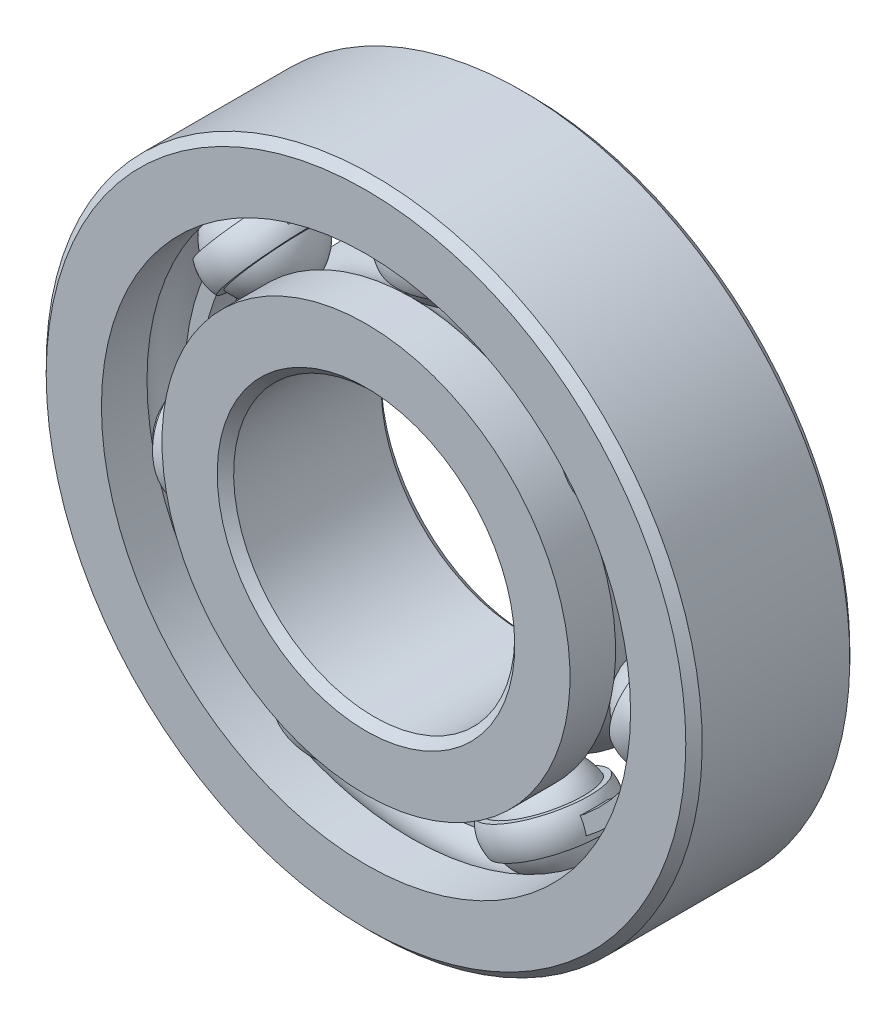
from build123d import *

# Parameters (mm, degrees)
CIRPATTERN1_COUNT   = 7
SKETCH9_R           = 8.450384615
SKETCH9_R_2         = 7.9375
BOSS_EXTRUDE1_DEPTH = 0.463020833


with BuildPart() as part:
    # Sketch7 → Revolve6 (revolve)
    with BuildSketch(Plane(origin=(0, 0, 0), x_dir=(0, 0, -1), z_dir=(1, 0, 0))):
        with BuildLine():
            Line((2.5003125, 11.1125), (2.778125, 10.8346875))
            Line((2.778125, 10.8346875), (2.778125, 8.963269231))
            Line((2.778125, 8.963269231), (1.234722222, 8.963269231))
            ThreePointArc((1.234722222, 8.963269231), (0, 9.542723187), (-1.234722222, 8.963269231))
            Line((-1.234722222, 8.963269231), (-2.778125, 8.963269231))
            Line((-2.778125, 8.963269231), (-2.778125, 10.8346875))
            Line((-2.778125, 10.8346875), (-2.5003125, 11.1125))
            Line((-2.5003125, 11.1125), (2.5003125, 11.1125))
        make_face()
    revolve(axis=Axis((0, 0, 2.778125), (0, 0, -1)))


with BuildPart() as body_2:
    # Sketch3 → Revolve3 (revolve)
    with BuildSketch(Plane(origin=(0, 0, 0), x_dir=(0, 0, -1), z_dir=(1, 0, 0))):
        with BuildLine():
            Line((-2.5003125, 4.7625), (-2.778125, 5.0403125))
            Line((-2.778125, 5.0403125), (-2.778125, 6.911730769))
            Line((-2.778125, 6.911730769), (-1.234722222, 6.911730769))
            ThreePointArc((-1.234722222, 6.911730769), (0, 6.332276813), (1.234722222, 6.911730769))
            Line((1.234722222, 6.911730769), (2.778125, 6.911730769))
            Line((2.778125, 6.911730769), (2.778125, 5.0403125))
            Line((2.778125, 5.0403125), (2.5003125, 4.7625))
            Line((2.5003125, 4.7625), (-2.5003125, 4.7625))
        make_face()
    revolve(axis=Axis((0, 0, 2.778125), (0, 0, -1)))


with BuildPart() as body_3:
    # Sketch4 → Revolve4 (revolve)
    with BuildSketch(Plane(origin=(0, 0, 0), x_dir=(0, 0, -1), z_dir=(1, 0, 0))):
        with BuildLine():
            Line((-1.605223187, 7.9375), (1.605223187, 7.9375))
            ThreePointArc((1.605223187, 7.9375), (0, 9.542723187), (-1.605223187, 7.9375))
        make_face()
    revolve(axis=Axis((0, 7.9375, 1.605223187), (0, 0, -1)))


with BuildPart() as body_4:
    # Sketch8 → Revolve7 (revolve)
    with BuildSketch(Plane(origin=(0, 0, 0), x_dir=(0, 0, -1), z_dir=(1, 0, 0))):
        with BuildLine():
            Line((-1.521082132, 8.450384615), (-1.730589277, 8.450384615))
            ThreePointArc((-1.730589277, 8.450384615), (-1.835342849, 7.9375), (-1.730589277, 7.424615385))
            Line((-1.730589277, 7.424615385), (-1.521082132, 7.424615385))
            ThreePointArc((-1.521082132, 7.424615385), (-1.605223187, 7.9375), (-1.521082132, 8.450384615))
        make_face()
    revolve(axis=Axis((0, 11.1125, 0), (0, -1, 0)))


with BuildPart() as cirpattern1_1:
    # CirPattern1: pattern copy
    add(body_4.part.rotate(Axis((0, 0, 0), (0, 0, 1)), 1 * 360 / CIRPATTERN1_COUNT))


with BuildPart() as cirpattern1_2:
    # CirPattern1: pattern copy
    add(body_4.part.rotate(Axis((0, 0, 0), (0, 0, 1)), 2 * 360 / CIRPATTERN1_COUNT))


with BuildPart() as cirpattern1_3:
    # CirPattern1: pattern copy
    add(body_4.part.rotate(Axis((0, 0, 0), (0, 0, 1)), 3 * 360 / CIRPATTERN1_COUNT))


with BuildPart() as cirpattern1_4:
    # CirPattern1: pattern copy
    add(body_4.part.rotate(Axis((0, 0, 0), (0, 0, 1)), 4 * 360 / CIRPATTERN1_COUNT))


with BuildPart() as cirpattern1_5:
    # CirPattern1: pattern copy
    add(body_4.part.rotate(Axis((0, 0, 0), (0, 0, 1)), 5 * 360 / CIRPATTERN1_COUNT))


with BuildPart() as cirpattern1_6:
    # CirPattern1: pattern copy
    add(body_4.part.rotate(Axis((0, 0, 0), (0, 0, 1)), 6 * 360 / CIRPATTERN1_COUNT))


with BuildPart() as cirpattern1_7:
    # CirPattern1: pattern copy
    add(body_3.part.rotate(Axis((0, 0, 0), (0, 0, 1)), 1 * 360 / CIRPATTERN1_COUNT))


with BuildPart() as cirpattern1_8:
    # CirPattern1: pattern copy
    add(body_3.part.rotate(Axis((0, 0, 0), (0, 0, 1)), 2 * 360 / CIRPATTERN1_COUNT))


with BuildPart() as cirpattern1_9:
    # CirPattern1: pattern copy
    add(body_3.part.rotate(Axis((0, 0, 0), (0, 0, 1)), 3 * 360 / CIRPATTERN1_COUNT))


with BuildPart() as cirpattern1_10:
    # CirPattern1: pattern copy
    add(body_3.part.rotate(Axis((0, 0, 0), (0, 0, 1)), 4 * 360 / CIRPATTERN1_COUNT))


with BuildPart() as cirpattern1_11:
    # CirPattern1: pattern copy
    add(body_3.part.rotate(Axis((0, 0, 0), (0, 0, 1)), 5 * 360 / CIRPATTERN1_COUNT))


with BuildPart() as cirpattern1_12:
    # CirPattern1: pattern copy
    add(body_3.part.rotate(Axis((0, 0, 0), (0, 0, 1)), 6 * 360 / CIRPATTERN1_COUNT))


with BuildPart() as body_17:
    # Sketch9 → Boss-Extrude1 (new body, symmetric)
    with BuildSketch(Plane.XY):
        Circle(SKETCH9_R)
        Circle(SKETCH9_R_2, mode=Mode.SUBTRACT)
    extrude(amount=BOSS_EXTRUDE1_DEPTH, both=True)


solid = Compound([part.part, body_2.part, body_3.part, body_4.part, cirpattern1_1.part, cirpattern1_2.part, cirpattern1_3.part, cirpattern1_4.part, cirpattern1_5.part, cirpattern1_6.part, cirpattern1_7.part, cirpattern1_8.part, cirpattern1_9.part, cirpattern1_10.part, cirpattern1_11.part, cirpattern1_12.part, body_17.part])
